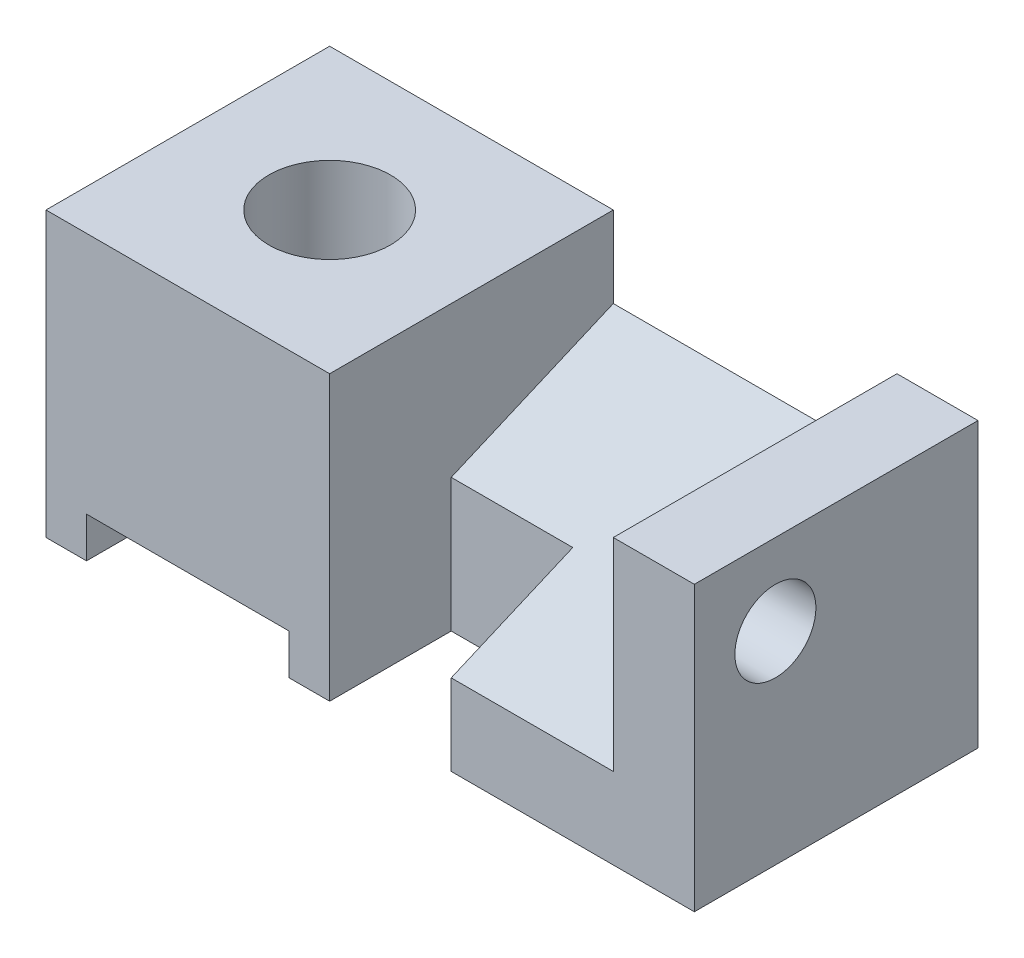
from build123d import *

# Parameters (mm, degrees)
SKETCH1_W               = 80
SKETCH1_H               = 35
BOSS_EXTRUDE1_DEPTH     = 35
CUT_EXTRUDE1_DEPTH      = 45
SKETCH3_W               = 35
SKETCH3_H               = 35
BOSS_EXTRUDE2_DEPTH     = 10
SKETCH4_W               = 15
SKETCH4_H               = 15
CUT_EXTRUDE2_DEPTH      = 1
CUT_EXTRUDE2_DEPTH_BACK = 36
SKETCH5_R               = 5
CUT_EXTRUDE3_DEPTH      = 10
SKETCH6_W               = 25
SKETCH6_H               = 5
CUT_EXTRUDE4_DEPTH      = 36
SKETCH7_R               = 7.5
CUT_EXTRUDE5_DEPTH      = 36


with BuildPart() as part:
    # Sketch1 → Boss-Extrude1 (new body)
    with BuildSketch(Plane(origin=(0, 0, 0), x_dir=(1, 0, 0), z_dir=(0, 1, 0))):
        with Locations((40, 17.5)):
            Rectangle(SKETCH1_W, SKETCH1_H)
    extrude(amount=BOSS_EXTRUDE1_DEPTH)

    # Sketch2 → Cut-Extrude1 (cut)
    with BuildSketch(Plane(origin=(80, 0, 0), x_dir=(0, 0, -1), z_dir=(1, 0, 0))):
        Polygon((35, 35), (35, 25), (0, 10), (0, 35), align=None)
    extrude(amount=-CUT_EXTRUDE1_DEPTH, mode=Mode.SUBTRACT)

    # Sketch3 → Boss-Extrude2 (add)
    with BuildSketch(Plane(origin=(80, 0, 0), x_dir=(0, 0, -1), z_dir=(1, 0, 0))):
        with Locations((17.5, 17.5)):
            Rectangle(SKETCH3_W, SKETCH3_H)
    extrude(amount=-BOSS_EXTRUDE2_DEPTH)

    # Sketch4 → Cut-Extrude2 (cut, two sides)
    with BuildSketch(Plane(origin=(0, 0, 0), x_dir=(-1, 0, 0), z_dir=(0, -1, 0))) as cut_extrude2_sk:
        with Locations((-42.5, 7.5)):
            Rectangle(SKETCH4_W, SKETCH4_H)
    extrude(amount=CUT_EXTRUDE2_DEPTH, mode=Mode.SUBTRACT)
    extrude(cut_extrude2_sk.sketch, amount=-CUT_EXTRUDE2_DEPTH_BACK, mode=Mode.SUBTRACT)

    # Sketch5 → Cut-Extrude3 (cut)
    with BuildSketch(Plane(origin=(80, 0, 0), x_dir=(0, 0, -1), z_dir=(1, 0, 0))):
        with Locations((10, 25)):
            Circle(SKETCH5_R)
    extrude(amount=-CUT_EXTRUDE3_DEPTH, mode=Mode.SUBTRACT)

    # Sketch6 → Cut-Extrude4 (cut, through all)
    with BuildSketch(Plane.XY):
        with Locations((17.5, 2.5)):
            Rectangle(SKETCH6_W, SKETCH6_H)
    extrude(amount=-CUT_EXTRUDE4_DEPTH, mode=Mode.SUBTRACT)

    # Sketch7 → Cut-Extrude5 (cut, through all)
    with BuildSketch(Plane(origin=(0, 35, 0), x_dir=(1, 0, 0), z_dir=(0, 1, 0))):
        with Locations((17.5, 17.5)):
            Circle(SKETCH7_R)
    extrude(amount=-CUT_EXTRUDE5_DEPTH, mode=Mode.SUBTRACT)


solid = part.part
